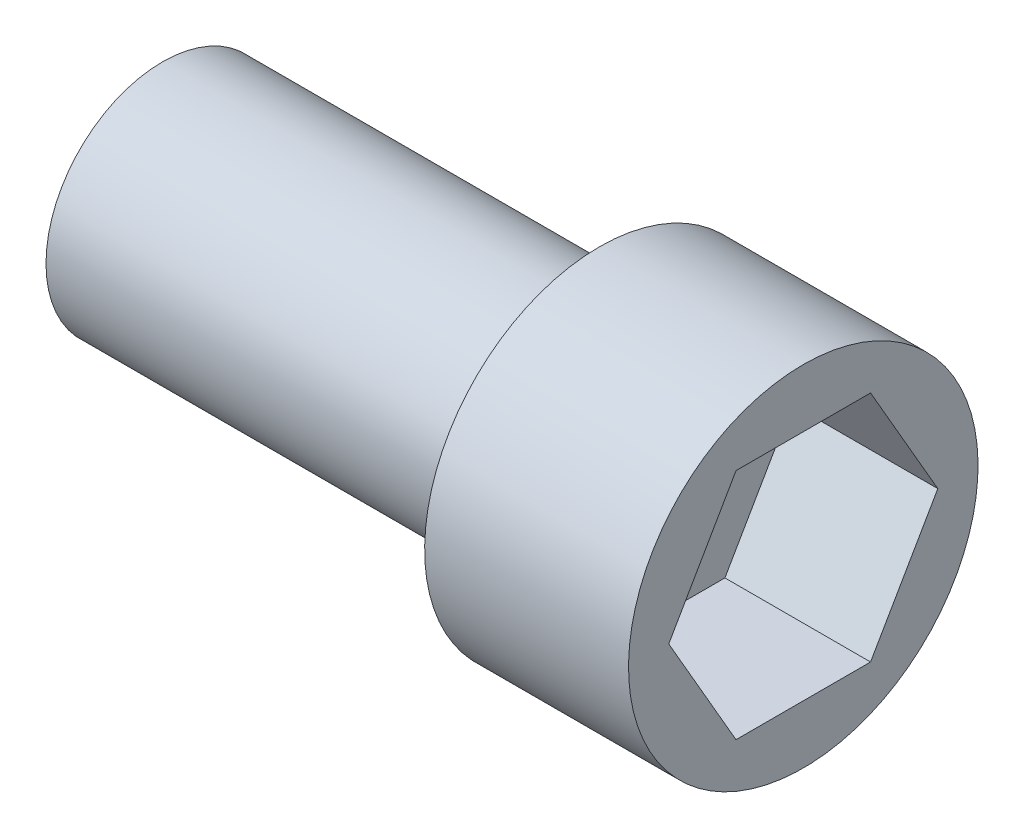
from build123d import *

# Parameters (mm, degrees)
CUT_EXTRUDE2_DEPTH = 5


with BuildPart() as part:
    # Sketch1 → Revolve1 (revolve)
    with BuildSketch(Plane.XY):
        Polygon((11, 0), (-11, 0), (-11, 4), (4, 4), (4, 6), (11, 6), align=None)
    revolve(axis=Axis((11, 0, 0), (-1, 0, 0)))

    # Sketch2 → Cut-Extrude2 (cut)
    with BuildSketch(Plane(origin=(11, 0, 0), x_dir=(0, 0, -1), z_dir=(1, 0, 0))):
        Polygon((4.618802154, 0), (2.309401077, 4), (-2.309401077, 4), (-4.618802154, 0), (-2.309401077, -4), (2.309401077, -4), align=None)
    extrude(amount=-CUT_EXTRUDE2_DEPTH, mode=Mode.SUBTRACT)


solid = part.part
